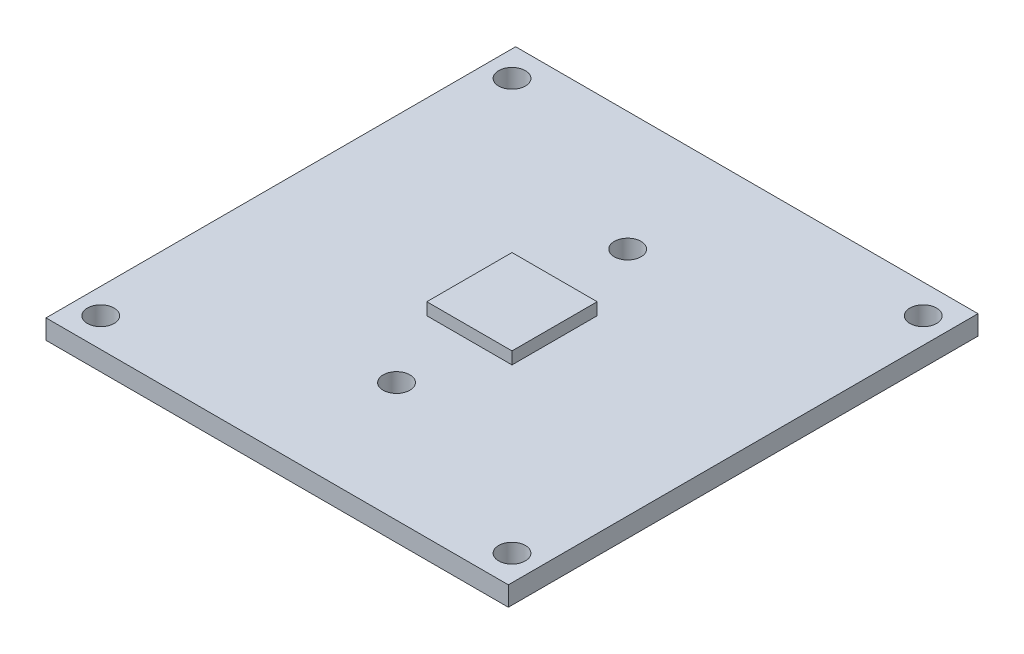
from build123d import *

# Parameters (mm, degrees)
SKETCH1_W               = 38
SKETCH1_H               = 38.6
SKETCH1_R               = 1.1
CAMERA_BOARD_BASE_DEPTH = 1.6
SKETCH1_3_W             = 32
SKETCH1_3_H             = 28.6
SKETCH1_3_R             = 2
COMPONENTS_DEPTH        = 2.3
SKETCH2_W               = 7
SKETCH2_H               = 7
SENSOR_DEPTH            = 1


with BuildPart() as part:
    # Sketch1 → Camera Board Base (new body)
    with BuildSketch(Plane(origin=(0, 0, 0), x_dir=(1, 0, 0), z_dir=(0, 1, 0))):
        Rectangle(SKETCH1_W, SKETCH1_H)
        with Locations((0.008140781, 9.5)):
            Circle(SKETCH1_R, mode=Mode.SUBTRACT)
        with Locations((0.008140781, -9.5)):
            Circle(SKETCH1_R, mode=Mode.SUBTRACT)
        with Locations((-16.9, -16.9)):
            Circle(SKETCH1_R, mode=Mode.SUBTRACT)
        with Locations((16.9, -16.9)):
            Circle(SKETCH1_R, mode=Mode.SUBTRACT)
        with Locations((-16.9, 16.9)):
            Circle(SKETCH1_R, mode=Mode.SUBTRACT)
        with Locations((16.9, 16.9)):
            Circle(SKETCH1_R, mode=Mode.SUBTRACT)
    extrude(amount=CAMERA_BOARD_BASE_DEPTH)

    # Sketch1_3 → Components (add)
    with BuildSketch(Plane(origin=(0, 0, 0), x_dir=(1, 0, 0), z_dir=(0, 1, 0))):
        Rectangle(SKETCH1_3_W, SKETCH1_3_H)
        with Locations((0.008140781, 9.5)):
            Circle(SKETCH1_3_R, mode=Mode.SUBTRACT)
        with Locations((0.008140781, -9.5)):
            Circle(SKETCH1_3_R, mode=Mode.SUBTRACT)
    extrude(amount=-COMPONENTS_DEPTH)

    # Sketch2 → Sensor (add)
    with BuildSketch(Plane(origin=(0, 1.6, 0), x_dir=(1, 0, 0), z_dir=(0, 1, 0))):
        Rectangle(SKETCH2_W, SKETCH2_H)
    extrude(amount=SENSOR_DEPTH)


solid = part.part
